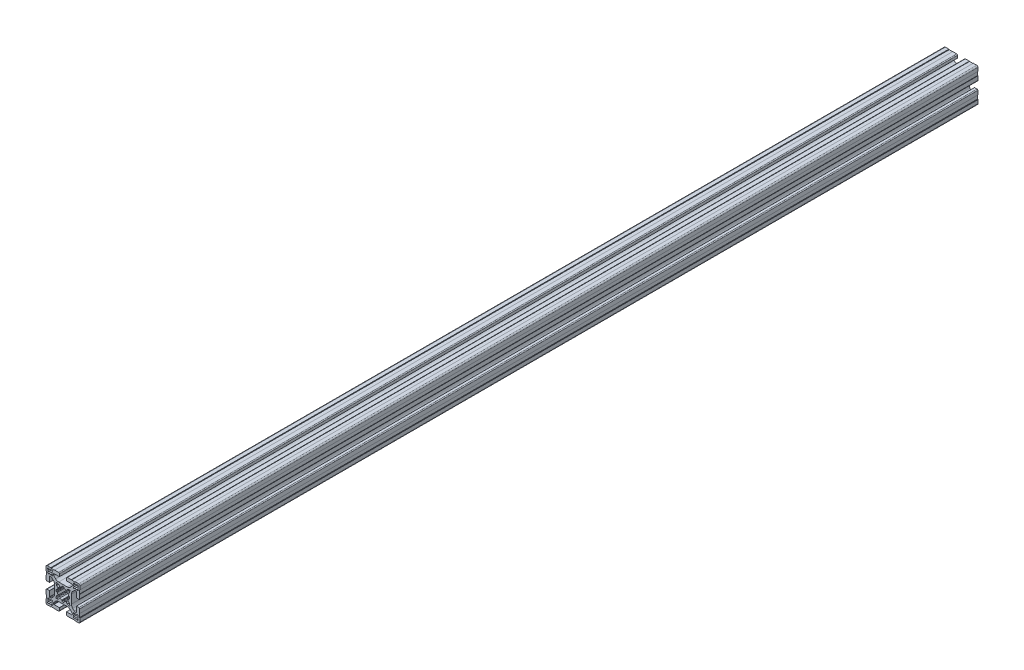
from build123d import *

# Parameters (mm, degrees)
RESSALTO_EXTRUS_O1_DEPTH = 530


with BuildPart() as part:
    # Esboço1 → Ressalto-extrusão1 (new body, symmetric)
    with BuildSketch(Plane.XY):
        with BuildLine():
            Line((4.14998475, -18.79998475), (4.14998475, -15.899980918))
            ThreePointArc((4.14998475, -15.899980918), (4.179274222, -15.829270089), (4.249985176, -15.799980918))
            Line((4.249985176, -15.799980918), (10.499997871, -15.800007531))
            ThreePointArc((10.499997871, -15.800007531), (10.853552638, -15.653561674), (11, -15.300007531))
            Line((11, -15.300007531), (11, -14.449747468))
            ThreePointArc((11, -14.449747468), (10.885819299, -13.87572232), (10.560660172, -13.389087297))
            Line((10.560660172, -13.389087297), (8.636038969, -11.464466094))
            ThreePointArc((8.636038969, -11.464466094), (7.013922225, -10.380602337), (5.100505063, -10))
            Line((5.100505063, -10), (0, -10))
            Line((0, -10), (-5.100505063, -10))
            ThreePointArc((-5.100505063, -10), (-7.013922225, -10.380602337), (-8.636038969, -11.464466094))
            Line((-8.636038969, -11.464466094), (-10.560660172, -13.389087297))
            ThreePointArc((-10.560660172, -13.389087297), (-10.885819299, -13.87572232), (-11, -14.449747468))
            Line((-11, -14.449747468), (-11, -15.300007531))
            ThreePointArc((-11, -15.300007531), (-10.853552638, -15.653561674), (-10.499997871, -15.800007531))
            Line((-10.499997871, -15.800007531), (-4.249985176, -15.799980918))
            ThreePointArc((-4.249985176, -15.799980918), (-4.179274222, -15.829270089), (-4.14998475, -15.899980918))
            Line((-4.14998475, -15.899980918), (-4.14998475, -18.79998475))
            ThreePointArc((-4.14998475, -18.79998475), (-4.442876463, -19.507090026), (-5.149980492, -19.79998475))
            Line((-5.149980492, -19.79998475), (-9.79996495, -19.80000455))
            Line((-9.79996495, -19.80000455), (-9.99998475, -19.59998475))
            Line((-9.99998475, -19.59998475), (-13.99998475, -19.59998475))
            Line((-13.99998475, -19.59998475), (-14.40000475, -20.00000475))
            Line((-14.40000475, -20.00000475), (-18.50000475, -20.00000475))
            ThreePointArc((-18.50000475, -20.00000475), (-19.560664922, -19.560664922), (-20.00000475, -18.50000475))
            Line((-20.00000475, -18.50000475), (-20.00000475, -14.40000475))
            Line((-20.00000475, -14.40000475), (-19.59998475, -13.99998475))
            Line((-19.59998475, -13.99998475), (-19.59998475, -9.99998475))
            Line((-19.59998475, -9.99998475), (-19.800004551, -9.799964949))
            Line((-19.800004551, -9.799964949), (-19.799984751, -5.149980488))
            ThreePointArc((-19.799984751, -5.149980488), (-19.507090026, -4.442876459), (-18.79998475, -4.149984746))
            Line((-18.79998475, -4.149984746), (-15.899980918, -4.149984746))
            ThreePointArc((-15.899980918, -4.149984746), (-15.829270089, -4.179274218), (-15.799980918, -4.249985172))
            Line((-15.799980918, -4.249985172), (-15.800007532, -10.499997871))
            ThreePointArc((-15.800007532, -10.499997871), (-15.653561675, -10.853552638), (-15.300007532, -11))
            Line((-15.300007532, -11), (-14.449747468, -11))
            ThreePointArc((-14.449747468, -11), (-13.87572232, -10.885819298), (-13.389087297, -10.560660171))
            Line((-13.389087297, -10.560660171), (-11.464466094, -8.636038969))
            ThreePointArc((-11.464466094, -8.636038969), (-10.380602337, -7.013922225), (-10, -5.100505063))
            Line((-10, -5.100505063), (-10, 0))
            Line((-10, 0), (-10, 5.100505064))
            ThreePointArc((-10, 5.100505064), (-10.380602337, 7.013922225), (-11.464466094, 8.63603897))
            Line((-11.464466094, 8.63603897), (-13.389087297, 10.560660172))
            ThreePointArc((-13.389087297, 10.560660172), (-13.87572232, 10.885819299), (-14.449747468, 11))
            Line((-14.449747468, 11), (-15.300007532, 11))
            ThreePointArc((-15.300007532, 11), (-15.653561675, 10.853552638), (-15.800007532, 10.499997871))
            Line((-15.800007532, 10.499997871), (-15.799980918, 4.249985172))
            ThreePointArc((-15.799980918, 4.249985172), (-15.829270089, 4.179274219), (-15.899980918, 4.149984747))
            Line((-15.899980918, 4.149984747), (-18.79998475, 4.149984747))
            ThreePointArc((-18.79998475, 4.149984747), (-19.507090026, 4.44287646), (-19.799984751, 5.149980488))
            Line((-19.799984751, 5.149980488), (-19.800004551, 9.79996495))
            Line((-19.800004551, 9.79996495), (-19.59998475, 9.999984751))
            Line((-19.59998475, 9.999984751), (-19.59998475, 13.999984751))
            Line((-19.59998475, 13.999984751), (-20.00000475, 14.400004751))
            Line((-20.00000475, 14.400004751), (-20.00000475, 18.500004751))
            ThreePointArc((-20.00000475, 18.500004751), (-19.560664922, 19.560664922), (-18.50000475, 20.000004751))
            Line((-18.50000475, 20.000004751), (-14.40000475, 20.000004751))
            Line((-14.40000475, 20.000004751), (-13.99998475, 19.599984751))
            Line((-13.99998475, 19.599984751), (-9.99998475, 19.599984751))
            Line((-9.99998475, 19.599984751), (-9.79996495, 19.800004551))
            Line((-9.79996495, 19.800004551), (-5.149980492, 19.799984751))
            ThreePointArc((-5.149980492, 19.799984751), (-4.442876463, 19.507090026), (-4.14998475, 18.799984751))
            Line((-4.14998475, 18.799984751), (-4.14998475, 15.899980918))
            ThreePointArc((-4.14998475, 15.899980918), (-4.179274222, 15.82927009), (-4.249985176, 15.799980918))
            Line((-4.249985176, 15.799980918), (-10.499997871, 15.800007531))
            ThreePointArc((-10.499997871, 15.800007531), (-10.853552638, 15.653561675), (-11, 15.300007531))
            Line((-11, 15.300007531), (-11, 14.449747469))
            ThreePointArc((-11, 14.449747469), (-10.885819299, 13.87572232), (-10.560660172, 13.389087297))
            Line((-10.560660172, 13.389087297), (-8.636038969, 11.464466095))
            ThreePointArc((-8.636038969, 11.464466095), (-7.013922225, 10.380602338), (-5.100505063, 10.000000001))
            Line((-5.100505063, 10.000000001), (0, 10.000000001))
            Line((0, 10.000000001), (5.100505063, 10.000000001))
            ThreePointArc((5.100505063, 10.000000001), (7.013922225, 10.380602338), (8.636038969, 11.464466095))
            Line((8.636038969, 11.464466095), (10.560660172, 13.389087297))
            ThreePointArc((10.560660172, 13.389087297), (10.885819299, 13.87572232), (11, 14.449747469))
            Line((11, 14.449747469), (11, 15.300007531))
            ThreePointArc((11, 15.300007531), (10.853552638, 15.653561675), (10.499997871, 15.800007531))
            Line((10.499997871, 15.800007531), (4.249985176, 15.799980918))
            ThreePointArc((4.249985176, 15.799980918), (4.179274222, 15.82927009), (4.14998475, 15.899980918))
            Line((4.14998475, 15.899980918), (4.14998475, 18.799984751))
            ThreePointArc((4.14998475, 18.799984751), (4.442876463, 19.507090026), (5.149980492, 19.799984751))
            Line((5.149980492, 19.799984751), (9.79996495, 19.800004551))
            Line((9.79996495, 19.800004551), (9.99998475, 19.599984751))
            Line((9.99998475, 19.599984751), (13.99998475, 19.599984751))
            Line((13.99998475, 19.599984751), (14.40000475, 20.000004751))
            Line((14.40000475, 20.000004751), (18.50000475, 20.000004751))
            ThreePointArc((18.50000475, 20.000004751), (19.560664922, 19.560664922), (20.00000475, 18.500004751))
            Line((20.00000475, 18.500004751), (20.00000475, 14.400004751))
            Line((20.00000475, 14.400004751), (19.59998475, 13.999984751))
            Line((19.59998475, 13.999984751), (19.59998475, 9.999984751))
            Line((19.59998475, 9.999984751), (19.800004551, 9.79996495))
            Line((19.800004551, 9.79996495), (19.799984751, 5.149980488))
            ThreePointArc((19.799984751, 5.149980488), (19.507090026, 4.44287646), (18.79998475, 4.149984747))
            Line((18.79998475, 4.149984747), (15.899980918, 4.149984747))
            ThreePointArc((15.899980918, 4.149984747), (15.829270089, 4.179274219), (15.799980918, 4.249985172))
            Line((15.799980918, 4.249985172), (15.800007532, 10.499997871))
            ThreePointArc((15.800007532, 10.499997871), (15.653561675, 10.853552638), (15.300007532, 11))
            Line((15.300007532, 11), (14.449747468, 11))
            ThreePointArc((14.449747468, 11), (13.87572232, 10.885819299), (13.389087297, 10.560660172))
            Line((13.389087297, 10.560660172), (11.464466094, 8.63603897))
            ThreePointArc((11.464466094, 8.63603897), (10.380602337, 7.013922225), (10, 5.100505064))
            Line((10, 5.100505064), (10, 0))
            Line((10, 0), (10, -5.100505063))
            ThreePointArc((10, -5.100505063), (10.380602337, -7.013922225), (11.464466094, -8.636038969))
            Line((11.464466094, -8.636038969), (13.389087297, -10.560660171))
            ThreePointArc((13.389087297, -10.560660171), (13.87572232, -10.885819298), (14.449747468, -11))
            Line((14.449747468, -11), (15.300007532, -11))
            ThreePointArc((15.300007532, -11), (15.653561675, -10.853552638), (15.800007532, -10.499997871))
            Line((15.800007532, -10.499997871), (15.799980918, -4.249985172))
            ThreePointArc((15.799980918, -4.249985172), (15.829270089, -4.179274218), (15.899980918, -4.149984746))
            Line((15.899980918, -4.149984746), (18.79998475, -4.149984746))
            ThreePointArc((18.79998475, -4.149984746), (19.507090026, -4.442876459), (19.799984751, -5.149980488))
            Line((19.799984751, -5.149980488), (19.800004551, -9.799964949))
            Line((19.800004551, -9.799964949), (19.59998475, -9.99998475))
            Line((19.59998475, -9.99998475), (19.59998475, -13.99998475))
            Line((19.59998475, -13.99998475), (20.00000475, -14.40000475))
            Line((20.00000475, -14.40000475), (20.00000475, -18.50000475))
            ThreePointArc((20.00000475, -18.50000475), (19.560664922, -19.560664922), (18.50000475, -20.00000475))
            Line((18.50000475, -20.00000475), (14.40000475, -20.00000475))
            Line((14.40000475, -20.00000475), (13.99998475, -19.59998475))
            Line((13.99998475, -19.59998475), (9.99998475, -19.59998475))
            Line((9.99998475, -19.59998475), (9.79996495, -19.80000455))
            Line((9.79996495, -19.80000455), (5.149980492, -19.79998475))
            ThreePointArc((5.149980492, -19.79998475), (4.442876463, -19.507090026), (4.14998475, -18.79998475))
        make_face()
        with BuildLine():
            Line((-17.857240871, 16.796580699), (-17.416672281, 16.356012109))
            ThreePointArc((-17.416672281, 16.356012109), (-17.7, 15.2), (-17.416672281, 14.04398789))
            Line((-17.416672281, 14.04398789), (-17.857240871, 13.603419301))
            ThreePointArc((-17.857240871, 13.603419301), (-17.857240871, 12.542759129), (-16.796580699, 12.542759129))
            Line((-16.796580699, 12.542759129), (-16.35601211, 12.983327719))
            ThreePointArc((-16.35601211, 12.983327719), (-15.2, 12.7), (-14.04398789, 12.983327719))
            Line((-14.04398789, 12.983327719), (-13.603419301, 12.542759129))
            ThreePointArc((-13.603419301, 12.542759129), (-12.542759129, 12.542759129), (-12.542759129, 13.603419301))
            Line((-12.542759129, 13.603419301), (-12.983327719, 14.04398789))
            ThreePointArc((-12.983327719, 14.04398789), (-12.7, 15.2), (-12.983327719, 16.356012109))
            Line((-12.983327719, 16.356012109), (-12.542759081, 16.796580747))
            ThreePointArc((-12.542759081, 16.796580747), (-12.542759081, 17.857240919), (-13.603419253, 17.857240919))
            Line((-13.603419253, 17.857240919), (-14.04398789, 17.416672281))
            ThreePointArc((-14.04398789, 17.416672281), (-15.2, 17.7), (-16.35601211, 17.416672281))
            Line((-16.35601211, 17.416672281), (-16.796580699, 17.857240871))
            ThreePointArc((-16.796580699, 17.857240871), (-17.857240871, 17.857240871), (-17.857240871, 16.796580699))
        make_face(mode=Mode.SUBTRACT)
        with BuildLine():
            Line((17.416672281, 14.04398789), (17.857240871, 13.603419301))
            ThreePointArc((17.857240871, 13.603419301), (17.857240871, 12.542759129), (16.796580699, 12.542759129))
            Line((16.796580699, 12.542759129), (16.35601211, 12.983327719))
            ThreePointArc((16.35601211, 12.983327719), (15.2, 12.7), (14.043987891, 12.983327719))
            Line((14.043987891, 12.983327719), (13.603419301, 12.542759129))
            ThreePointArc((13.603419301, 12.542759129), (12.542759129, 12.542759129), (12.542759129, 13.603419301))
            Line((12.542759129, 13.603419301), (12.983327719, 14.04398789))
            ThreePointArc((12.983327719, 14.04398789), (12.7, 15.2), (12.983327719, 16.356012109))
            Line((12.983327719, 16.356012109), (12.542759081, 16.796580747))
            ThreePointArc((12.542759081, 16.796580747), (12.542759081, 17.857240919), (13.603419253, 17.857240919))
            Line((13.603419253, 17.857240919), (14.043987891, 17.416672281))
            ThreePointArc((14.043987891, 17.416672281), (15.2, 17.7), (16.35601211, 17.416672281))
            Line((16.35601211, 17.416672281), (16.796580699, 17.857240871))
            ThreePointArc((16.796580699, 17.857240871), (17.857240871, 17.857240871), (17.857240871, 16.796580699))
            Line((17.857240871, 16.796580699), (17.416672281, 16.356012109))
            ThreePointArc((17.416672281, 16.356012109), (17.7, 15.2), (17.416672281, 14.04398789))
        make_face(mode=Mode.SUBTRACT)
        with BuildLine():
            Line((-17.416672281, -14.04398789), (-17.857240871, -13.603419301))
            ThreePointArc((-17.857240871, -13.603419301), (-17.857240871, -12.542759129), (-16.796580699, -12.542759129))
            Line((-16.796580699, -12.542759129), (-16.35601211, -12.983327719))
            ThreePointArc((-16.35601211, -12.983327719), (-15.2, -12.7), (-14.04398789, -12.983327719))
            Line((-14.04398789, -12.983327719), (-13.603419301, -12.542759129))
            ThreePointArc((-13.603419301, -12.542759129), (-12.542759129, -12.542759129), (-12.542759129, -13.603419301))
            Line((-12.542759129, -13.603419301), (-12.983327719, -14.04398789))
            ThreePointArc((-12.983327719, -14.04398789), (-12.7, -15.2), (-12.983327719, -16.35601211))
            Line((-12.983327719, -16.35601211), (-12.542759081, -16.796580747))
            ThreePointArc((-12.542759081, -16.796580747), (-12.542759081, -17.857240919), (-13.603419253, -17.857240919))
            Line((-13.603419253, -17.857240919), (-14.04398789, -17.416672281))
            ThreePointArc((-14.04398789, -17.416672281), (-15.2, -17.7), (-16.35601211, -17.416672281))
            Line((-16.35601211, -17.416672281), (-16.796580699, -17.857240871))
            ThreePointArc((-16.796580699, -17.857240871), (-17.857240871, -17.857240871), (-17.857240871, -16.796580699))
            Line((-17.857240871, -16.796580699), (-17.416672281, -16.35601211))
            ThreePointArc((-17.416672281, -16.35601211), (-17.7, -15.2), (-17.416672281, -14.04398789))
        make_face(mode=Mode.SUBTRACT)
        with BuildLine():
            Line((17.857240871, -16.796580699), (17.416672281, -16.35601211))
            ThreePointArc((17.416672281, -16.35601211), (17.7, -15.2), (17.416672281, -14.04398789))
            Line((17.416672281, -14.04398789), (17.857240871, -13.603419301))
            ThreePointArc((17.857240871, -13.603419301), (17.857240871, -12.542759129), (16.796580699, -12.542759129))
            Line((16.796580699, -12.542759129), (16.35601211, -12.983327719))
            ThreePointArc((16.35601211, -12.983327719), (15.2, -12.7), (14.043987891, -12.983327719))
            Line((14.043987891, -12.983327719), (13.603419301, -12.542759129))
            ThreePointArc((13.603419301, -12.542759129), (12.542759129, -12.542759129), (12.542759129, -13.603419301))
            Line((12.542759129, -13.603419301), (12.983327719, -14.04398789))
            ThreePointArc((12.983327719, -14.04398789), (12.7, -15.2), (12.983327719, -16.35601211))
            Line((12.983327719, -16.35601211), (12.542759081, -16.796580747))
            ThreePointArc((12.542759081, -16.796580747), (12.542759081, -17.857240919), (13.603419253, -17.857240919))
            Line((13.603419253, -17.857240919), (14.043987891, -17.416672281))
            ThreePointArc((14.043987891, -17.416672281), (15.2, -17.7), (16.35601211, -17.416672281))
            Line((16.35601211, -17.416672281), (16.796580699, -17.857240871))
            ThreePointArc((16.796580699, -17.857240871), (17.857240871, -17.857240871), (17.857240871, -16.796580699))
        make_face(mode=Mode.SUBTRACT)
        with BuildLine():
            Line((-5.31389005, -7.63550963), (-7.648765071, -8.261137506))
            ThreePointArc((-7.648765071, -8.261137506), (-8.131727984, -8.131727984), (-8.261137506, -7.64876507))
            Line((-8.261137506, -7.64876507), (-7.63550963, -5.313890049))
            ThreePointArc((-7.63550963, -5.313890049), (-7.568281523, -5.165514456), (-7.456927431, -5.046622902))
            Line((-7.456927431, -5.046622902), (-5.743958929, -3.73221594))
            ThreePointArc((-5.743958929, -3.73221594), (-6.328574798, -2.621381512), (-6.70066751, -1.422517109))
            Line((-6.70066751, -1.422517109), (-7.520425705, -1.314593895))
            ThreePointArc((-7.520425705, -1.314593895), (-7.812495975, -1.168604027), (-7.952173449, -0.873462896))
            ThreePointArc((-7.952173449, -0.873462896), (-8, 0), (-7.952173449, 0.873462896))
            ThreePointArc((-7.952173449, 0.873462896), (-7.812495975, 1.168604027), (-7.520425705, 1.314593895))
            Line((-7.520425705, 1.314593895), (-6.70066751, 1.422517109))
            ThreePointArc((-6.70066751, 1.422517109), (-6.328574798, 2.621381512), (-5.743958929, 3.73221594))
            Line((-5.743958929, 3.73221594), (-7.456927431, 5.046622902))
            ThreePointArc((-7.456927431, 5.046622902), (-7.568281523, 5.165514456), (-7.63550963, 5.313890049))
            Line((-7.63550963, 5.313890049), (-8.261137506, 7.64876507))
            ThreePointArc((-8.261137506, 7.64876507), (-8.131727984, 8.131727984), (-7.648765071, 8.261137506))
            Line((-7.648765071, 8.261137506), (-5.31389005, 7.63550963))
            ThreePointArc((-5.31389005, 7.63550963), (-5.165514456, 7.568281523), (-5.046622902, 7.456927431))
            Line((-5.046622902, 7.456927431), (-3.73221594, 5.743958929))
            ThreePointArc((-3.73221594, 5.743958929), (-2.621381512, 6.328574798), (-1.422517109, 6.70066751))
            Line((-1.422517109, 6.70066751), (-1.314593895, 7.520425705))
            ThreePointArc((-1.314593895, 7.520425705), (-1.168604027, 7.812495975), (-0.873462896, 7.952173449))
            ThreePointArc((-0.873462896, 7.952173449), (0, 8), (0.873462896, 7.952173449))
            ThreePointArc((0.873462896, 7.952173449), (1.168604027, 7.812495975), (1.314593895, 7.520425705))
            Line((1.314593895, 7.520425705), (1.422517109, 6.70066751))
            ThreePointArc((1.422517109, 6.70066751), (2.621381512, 6.328574798), (3.73221594, 5.743958929))
            Line((3.73221594, 5.743958929), (5.046622902, 7.456927431))
            ThreePointArc((5.046622902, 7.456927431), (5.165514456, 7.568281523), (5.31389005, 7.63550963))
            Line((5.31389005, 7.63550963), (7.648765071, 8.261137506))
            ThreePointArc((7.648765071, 8.261137506), (8.131727984, 8.131727984), (8.261137506, 7.64876507))
            Line((8.261137506, 7.64876507), (7.63550963, 5.313890049))
            ThreePointArc((7.63550963, 5.313890049), (7.568281523, 5.165514456), (7.456927431, 5.046622902))
            Line((7.456927431, 5.046622902), (5.743958929, 3.73221594))
            ThreePointArc((5.743958929, 3.73221594), (6.328574798, 2.621381512), (6.70066751, 1.422517109))
            Line((6.70066751, 1.422517109), (7.520425705, 1.314593895))
            ThreePointArc((7.520425705, 1.314593895), (7.812495975, 1.168604027), (7.952173449, 0.873462896))
            ThreePointArc((7.952173449, 0.873462896), (8, 0), (7.952173449, -0.873462896))
            ThreePointArc((7.952173449, -0.873462896), (7.812495975, -1.168604027), (7.520425705, -1.314593895))
            Line((7.520425705, -1.314593895), (6.70066751, -1.422517109))
            ThreePointArc((6.70066751, -1.422517109), (6.328574798, -2.621381512), (5.743958929, -3.73221594))
            Line((5.743958929, -3.73221594), (7.456927431, -5.046622902))
            ThreePointArc((7.456927431, -5.046622902), (7.568281523, -5.165514456), (7.63550963, -5.313890049))
            Line((7.63550963, -5.313890049), (8.261137506, -7.64876507))
            ThreePointArc((8.261137506, -7.64876507), (8.131727984, -8.131727984), (7.648765071, -8.261137506))
            Line((7.648765071, -8.261137506), (5.31389005, -7.63550963))
            ThreePointArc((5.31389005, -7.63550963), (5.165514456, -7.568281523), (5.046622902, -7.456927431))
            Line((5.046622902, -7.456927431), (3.73221594, -5.743958929))
            ThreePointArc((3.73221594, -5.743958929), (2.621381512, -6.328574798), (1.422517109, -6.70066751))
            Line((1.422517109, -6.70066751), (1.314593895, -7.520425705))
            ThreePointArc((1.314593895, -7.520425705), (1.168604027, -7.812495975), (0.873462896, -7.952173449))
            ThreePointArc((0.873462896, -7.952173449), (0, -8), (-0.873462896, -7.952173449))
            ThreePointArc((-0.873462896, -7.952173449), (-1.168604027, -7.812495975), (-1.314593895, -7.520425705))
            Line((-1.314593895, -7.520425705), (-1.422517109, -6.70066751))
            ThreePointArc((-1.422517109, -6.70066751), (-2.621381512, -6.328574798), (-3.73221594, -5.743958929))
            Line((-3.73221594, -5.743958929), (-5.046622902, -7.456927431))
            ThreePointArc((-5.046622902, -7.456927431), (-5.165514456, -7.568281523), (-5.31389005, -7.63550963))
        make_face(mode=Mode.SUBTRACT)
    extrude(amount=RESSALTO_EXTRUS_O1_DEPTH, both=True)


solid = part.part
